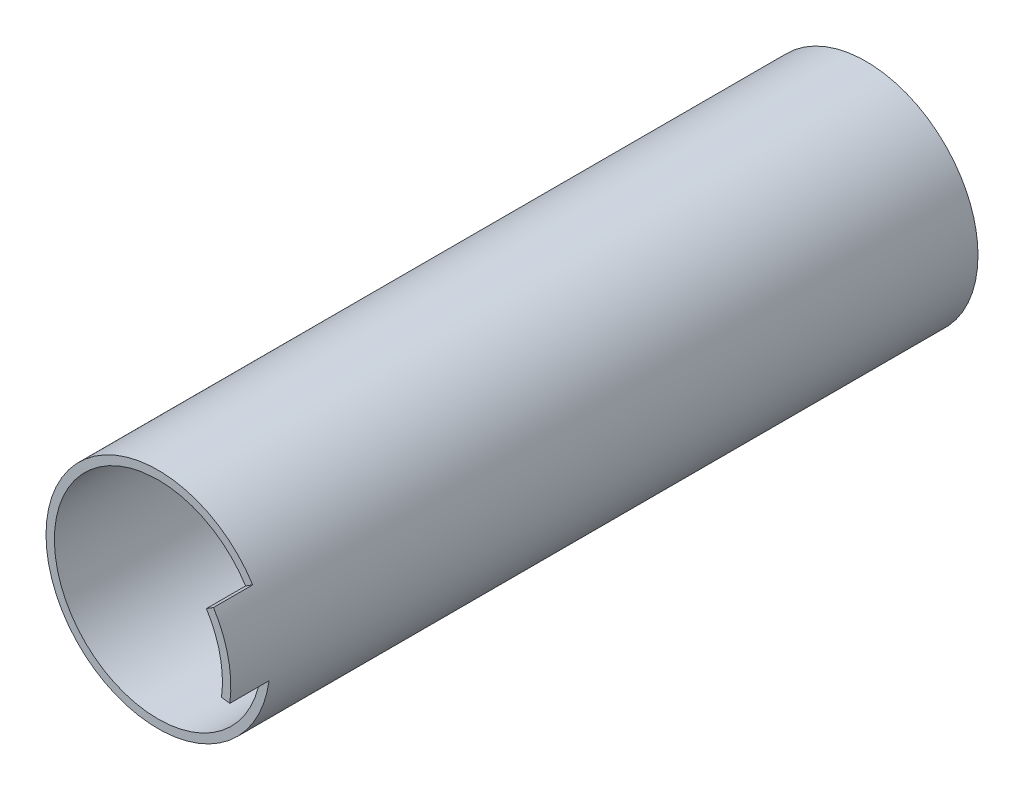
from build123d import *

# Parameters (mm, degrees)
SKETCH_2_R          = 20
SKETCH_2_R_2        = 18.5
EXTRUDE_1_DEPTH     = 126.4
SKETCH_5_R          = 3
EXTRUDE_3_DEPTH     = 126.4
CUT_EXTRUDE1_DEPTH  = 59
CUT_EXTRUDE2_DEPTH  = 59
BOSS_EXTRUDE4_DEPTH = 7
SKETCH3_R           = 3
BOSS_EXTRUDE6_DEPTH = 58.6


with BuildPart() as part:
    # Эскиз2 → Бобышка-Вытянуть1 (new body)
    with BuildSketch(Plane.XY):
        Circle(SKETCH_2_R)
        Circle(SKETCH_2_R_2, mode=Mode.SUBTRACT)
    extrude(amount=EXTRUDE_1_DEPTH)

    # Эскиз5 → Бобышка-Вытянуть3 (add, through all)
    with BuildSketch(Plane(origin=(0, 0, 0), x_dir=(-1, 0, 0), z_dir=(0, 0, -1))):
        with BuildLine():
            Line((0, 18.5), (0, 9.219544457))
            ThreePointArc((0, 9.219544457), (-0.725705562, 6.35915669), (-2.727272727, 4.190702026))
            ThreePointArc((-2.727272727, 4.190702026), (-0.405405405, -4.983537544), (3.368749585, 3.694797184))
            ThreePointArc((3.368749585, 3.694797184), (1.743983113, 6.158250179), (1.490138787, 9.098323274))
            Line((1.490138787, 9.098323274), (2.990122527, 18.256756757))
            ThreePointArc((2.990122527, 18.256756757), (1.5, 18.439088915), (0, 18.5))
        make_face()
        Circle(SKETCH_5_R, mode=Mode.SUBTRACT)
    extrude(amount=-EXTRUDE_3_DEPTH)

    # Sketch1 → Cut-Extrude1 (cut)
    with BuildSketch(Plane(origin=(0, 0, 0), x_dir=(-1, 0, 0), z_dir=(0, 0, -1))):
        with BuildLine():
            Line((0, 18.5), (2.990122527, 18.256756757))
            ThreePointArc((2.990122527, 18.256756757), (-1.5, -18.439088915), (0, 18.5))
        make_face()
    extrude(amount=-CUT_EXTRUDE1_DEPTH, mode=Mode.SUBTRACT)

    # Sketch2 → Cut-Extrude2 (cut)
    with BuildSketch(Plane.XY.offset(126.4)):
        with BuildLine():
            Line((0, 18.5), (-2.990122527, 18.256756757))
            ThreePointArc((-2.990122527, 18.256756757), (1.50000041, -18.439093959), (0, 18.5))
        make_face()
    extrude(amount=-CUT_EXTRUDE2_DEPTH, mode=Mode.SUBTRACT)

    # Sketch6 → Boss-Extrude4 (add)
    with BuildSketch(Plane.XY.offset(126.4)):
        with BuildLine():
            Line((16.901505151, 10.692947377), (15.633892265, 9.890976324))
            ThreePointArc((15.633892265, 9.890976324), (18.073966336, 3.947371391), (18.334053323, -2.472344789))
            Line((18.334053323, -2.472344789), (19.820598187, -2.672805177))
            ThreePointArc((19.820598187, -2.672805177), (19.539423066, 4.267428531), (16.901505151, 10.692947377))
        make_face()
    extrude(amount=BOSS_EXTRUDE4_DEPTH)


with BuildPart() as body_2:
    # Sketch3 → Boss-Extrude6 (new body)
    with BuildSketch(Plane.XY):
        with BuildLine():
            Line((5, 0), (5, 16.770509831))
            ThreePointArc((5, 16.770509831), (0, 17.5), (-5, 16.770509831))
            Line((-5, 16.770509831), (-5, 0))
            ThreePointArc((-5, 0), (0, -5), (5, 0))
        make_face()
        Circle(SKETCH3_R, mode=Mode.SUBTRACT)
    extrude(amount=BOSS_EXTRUDE6_DEPTH)


solid = Compound([part.part, body_2.part])
